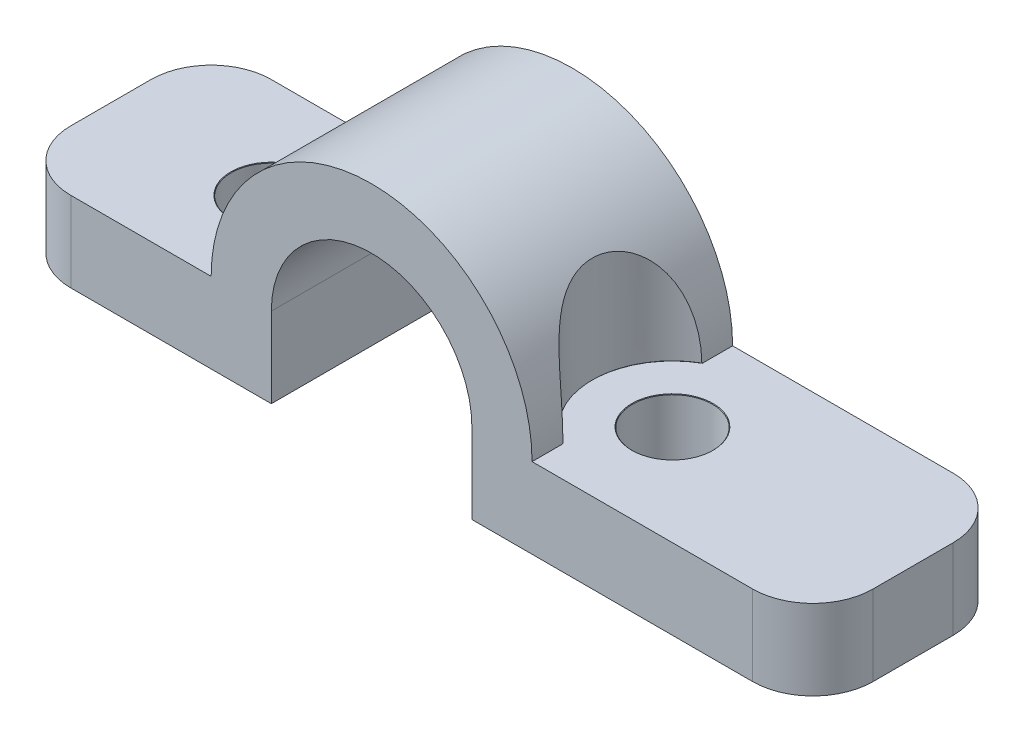
from build123d import *

# Parameters (mm, degrees)
BOSS_EXTRUDE1_DEPTH            = 5
BOSS_EXTRUDE1_DEPTH_BACK       = 5
F_4_0MM_DOWEL_HOLE2_AT_2_COUNT = 2
F_4_0MM_DOWEL_HOLE2_AT_2_PITCH = 20
FILLET1_R                      = 3
F_8_0MM_DOWEL_HOLE1_AT_2_COUNT = 2
F_8_0MM_DOWEL_HOLE1_AT_2_PITCH = 20


with BuildPart() as part:
    # Sketch1 → Boss-Extrude1 (new, two sides: drawn at the far end of the back side and taken through both)
    with BuildSketch(Plane.XY.offset(-BOSS_EXTRUDE1_DEPTH_BACK)):
        with BuildLine():
            Line((-18, 0), (-5, 0))
            Line((-5, 0), (-5, 4))
            ThreePointArc((-5, 4), (0, 9), (5, 4))
            Line((5, 4), (5, 0))
            Line((5, 0), (22, 0))
            Line((22, 0), (22, 4))
            Line((22, 4), (8, 4))
            ThreePointArc((8, 4), (0, 12), (-8, 4))
            Line((-8, 4), (-18, 4))
            Line((-18, 4), (-18, 0))
        make_face()
    extrude(amount=BOSS_EXTRUDE1_DEPTH + BOSS_EXTRUDE1_DEPTH_BACK)

    # Sketch7 → Ø4.0mm Dowel Hole2 (revolve, cut)
    with BuildSketch(Plane(origin=(10, 4, 0), x_dir=(0, 0, 1), z_dir=(1, 0, 0))):
        Polygon((0, 0), (0, 4), (2, 4), (2, 0.025), (2.025, 0), align=None)
    f_4_0mm_dowel_hole2 = revolve(axis=Axis((10, 10.35, 0), (0, -1, 0)), mode=Mode.SUBTRACT)

    # Ø4.0mm Dowel Hole2 at 2: Ø4.0mm Dowel Hole2 ×2
    with Locations(*[(-i * F_4_0MM_DOWEL_HOLE2_AT_2_PITCH, 0, 0) for i in range(1, F_4_0MM_DOWEL_HOLE2_AT_2_COUNT)]):
        add(f_4_0mm_dowel_hole2, mode=Mode.SUBTRACT)

    # Fillet1
    fillet1_edges = [part.edges().sort_by_distance(p)[0] for p in [
        (22, 2, 5),
        (-18, 2, 5),
        (22, 2, -5),
        (-18, 2, -5),
    ]]
    fillet(fillet1_edges, radius=FILLET1_R)

    # Sketch10 → Ø8.0mm Dowel Hole1 (revolve, cut)
    with BuildSketch(Plane(origin=(-10, 4, 0), x_dir=(0, 0, -1), z_dir=(1, 0, 0))):
        Polygon((0, 0), (0, 8), (4, 8), (4, 0.025), (4.025, 0), align=None)
    f_8_0mm_dowel_hole1 = revolve(axis=Axis((-10, -2.35, 0), (0, 1, 0)), mode=Mode.SUBTRACT)

    # Ø8.0mm Dowel Hole1 at 2: Ø8.0mm Dowel Hole1 ×2
    with Locations(*[(i * F_8_0MM_DOWEL_HOLE1_AT_2_PITCH, 0, 0) for i in range(1, F_8_0MM_DOWEL_HOLE1_AT_2_COUNT)]):
        add(f_8_0mm_dowel_hole1, mode=Mode.SUBTRACT)


solid = part.part
